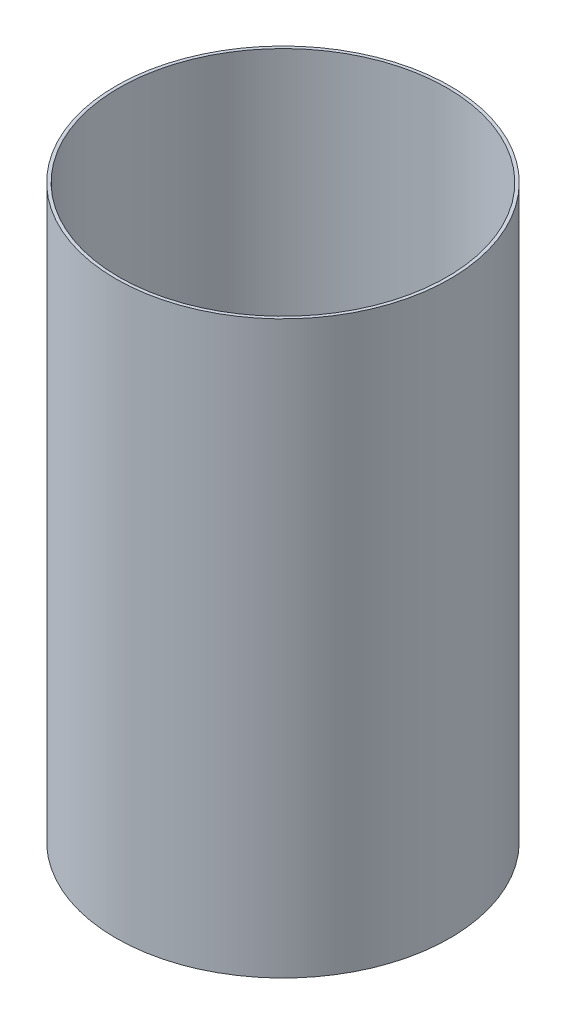
from build123d import *

# Parameters (mm, degrees)
SKETCH1_R           = 33.0835
SKETCH1_R_2         = 32.4612
BOSS_EXTRUDE1_DEPTH = 113.03


with BuildPart() as part:
    # Sketch1 → Boss-Extrude1 (new body)
    with BuildSketch(Plane(origin=(0, 0, 0), x_dir=(1, 0, 0), z_dir=(0, 1, 0))):
        Circle(SKETCH1_R)
        Circle(SKETCH1_R_2, mode=Mode.SUBTRACT)
    extrude(amount=BOSS_EXTRUDE1_DEPTH)


solid = part.part
